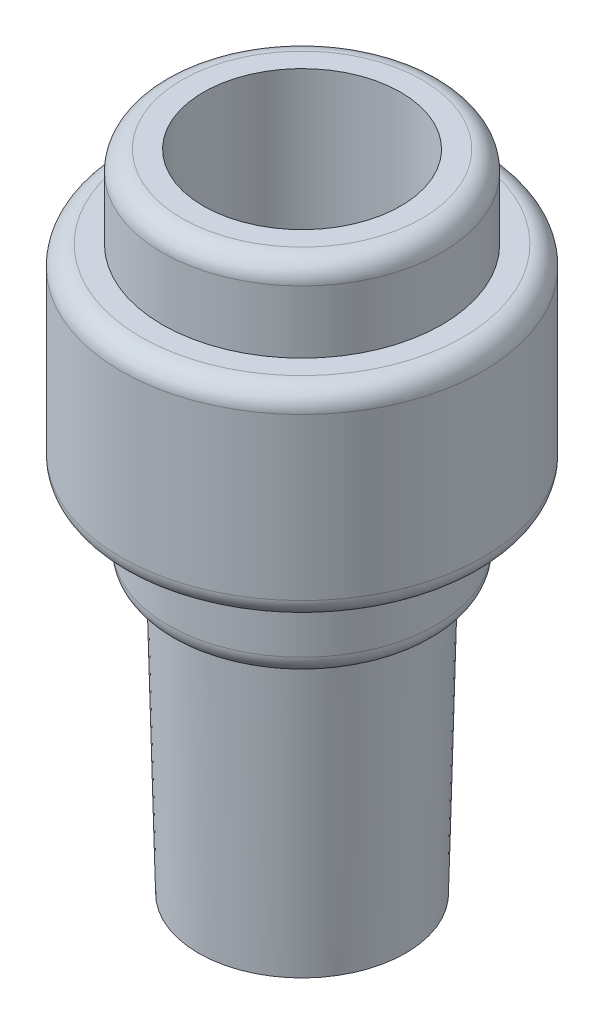
from build123d import *

# Parameters (mm, degrees)
SKETCH1_R           = 3.15
BOSS_EXTRUDE1_DEPTH = 8.5
BOSS_EXTRUDE1_TAPER = -1.35
SKETCH2_R           = 4.075
BOSS_EXTRUDE2_DEPTH = 2.5
SKETCH3_R           = 5.5
BOSS_EXTRUDE3_DEPTH = 6.1
SKETCH4_R           = 4.25
BOSS_EXTRUDE4_DEPTH = 2.5
SKETCH5_R           = 3
CUT_EXTRUDE1_DEPTH  = 6.5
SKETCH6_R           = 1.5
CUT_EXTRUDE2_DEPTH  = 13.1
FILLET1_R           = 0.6


with BuildPart() as part:
    # Sketch1 → Boss-Extrude1 (new body)
    with BuildSketch(Plane(origin=(0, 0, 0), x_dir=(1, 0, 0), z_dir=(0, 1, 0))):
        Circle(SKETCH1_R)
    extrude(amount=BOSS_EXTRUDE1_DEPTH, taper=BOSS_EXTRUDE1_TAPER)

    # Sketch2 → Boss-Extrude2 (add)
    with BuildSketch(Plane(origin=(0, 8.5, 0), x_dir=(1, 0, 0), z_dir=(0, 1, 0))):
        Circle(SKETCH2_R)
    extrude(amount=BOSS_EXTRUDE2_DEPTH)

    # Sketch3 → Boss-Extrude3 (add)
    with BuildSketch(Plane(origin=(0, 11, 0), x_dir=(1, 0, 0), z_dir=(0, 1, 0))):
        Circle(SKETCH3_R)
    extrude(amount=BOSS_EXTRUDE3_DEPTH)

    # Sketch4 → Boss-Extrude4 (add)
    with BuildSketch(Plane(origin=(0, 17.1, 0), x_dir=(1, 0, 0), z_dir=(0, 1, 0))):
        Circle(SKETCH4_R)
    extrude(amount=BOSS_EXTRUDE4_DEPTH)

    # Sketch5 → Cut-Extrude1 (cut)
    with BuildSketch(Plane(origin=(0, 19.6, 0), x_dir=(1, 0, 0), z_dir=(0, 1, 0))):
        Circle(SKETCH5_R)
    extrude(amount=-CUT_EXTRUDE1_DEPTH, mode=Mode.SUBTRACT)

    # Sketch6 → Cut-Extrude2 (cut)
    with BuildSketch(Plane.XZ):
        Circle(SKETCH6_R)
    extrude(amount=-CUT_EXTRUDE2_DEPTH, mode=Mode.SUBTRACT)

    # Fillet1
    fillet1_edges = [part.edges().sort_by_distance(p)[0] for p in [
        (-5.5, 17.1, 0),
        (-4.25, 19.6, 0),
        (-4.075, 8.5, 0),
        (-5.5, 11, 0),
    ]]
    fillet(fillet1_edges, radius=FILLET1_R)


solid = part.part
